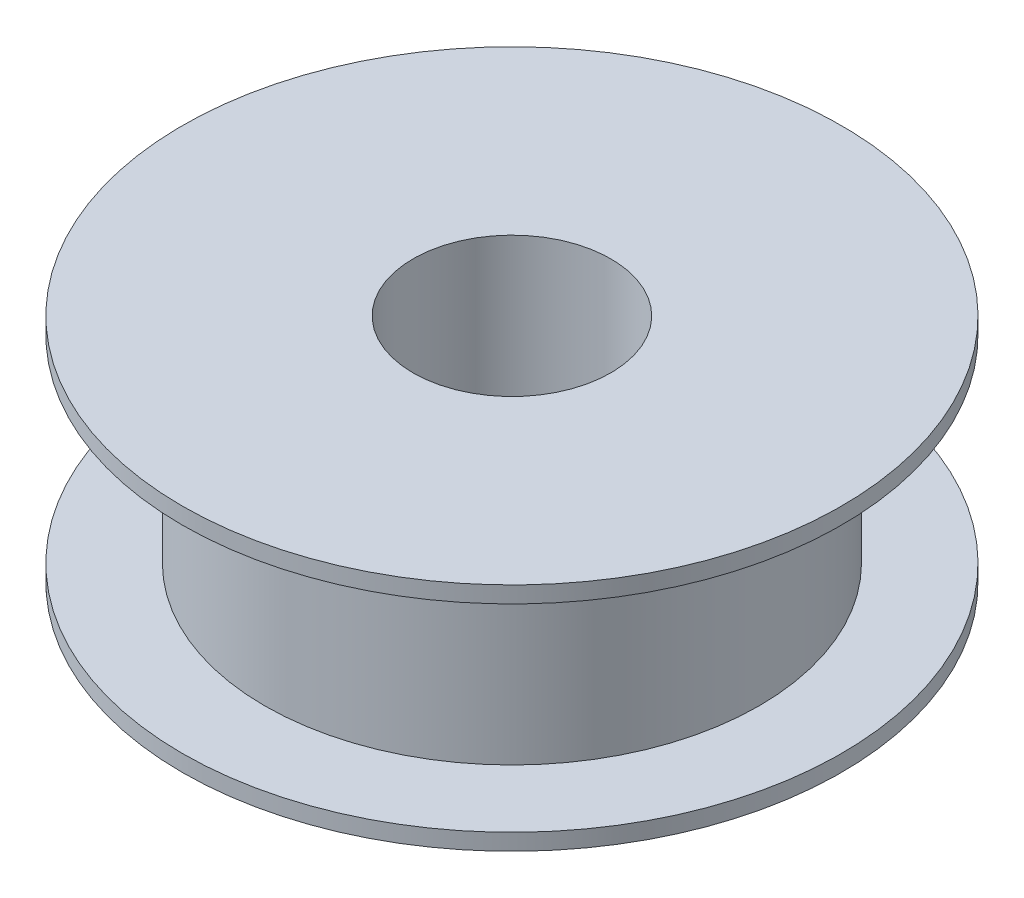
from build123d import *

# Parameters (mm, degrees)
ESQUISSE1_R        = 20
ESQUISSE1_R_2      = 6
BOSS_EXTRU_1_DEPTH = 1
BOSS_EXTRU_2_START = 12
ESQUISSE1_3_R      = 15
ESQUISSE1_3_R_2    = 6
BOSS_EXTRU_2_DEPTH = 12
BOSS_EXTRU_4_START = 1
ESQUISSE2_R        = 20
ESQUISSE2_R_2      = 6
BOSS_EXTRU_4_DEPTH = 1


with BuildPart() as part:
    # Esquisse1 → Boss.-Extru.1 (new body)
    with BuildSketch(Plane(origin=(0, 0, 0), x_dir=(1, 0, 0), z_dir=(0, 1, 0))):
        Circle(ESQUISSE1_R)
        Circle(ESQUISSE1_R_2, mode=Mode.SUBTRACT)
    extrude(amount=-BOSS_EXTRU_1_DEPTH)

    # Esquisse1_3 → Boss.-Extru.2 (add)
    with BuildSketch(Plane(origin=(0, 0, 0), x_dir=(1, 0, 0), z_dir=(0, 1, 0)).offset(BOSS_EXTRU_2_START)):
        Circle(ESQUISSE1_3_R)
        Circle(ESQUISSE1_3_R_2, mode=Mode.SUBTRACT)
    extrude(amount=-BOSS_EXTRU_2_DEPTH)

    # Esquisse2 → Boss.-Extru.4 (add)
    with BuildSketch(Plane(origin=(0, 12, 0), x_dir=(1, 0, 0), z_dir=(0, 1, 0)).offset(BOSS_EXTRU_4_START)):
        Circle(ESQUISSE2_R)
        Circle(ESQUISSE2_R_2, mode=Mode.SUBTRACT)
    extrude(amount=-BOSS_EXTRU_4_DEPTH)


solid = part.part
